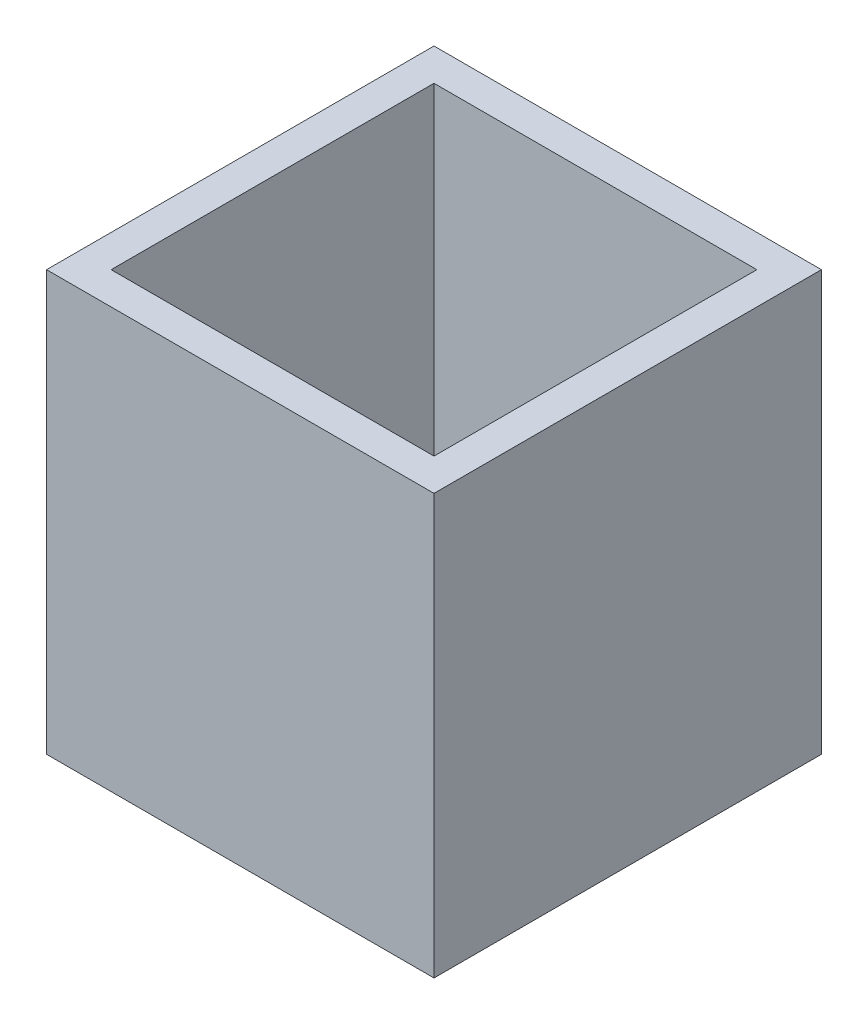
from build123d import *

# Parameters (mm, degrees)
SKETCH1_W           = 60
SKETCH1_H           = 60
SKETCH1_W_2         = 50
SKETCH1_H_2         = 50
BOSS_EXTRUDE1_DEPTH = 60
SKETCH2_W           = 60
SKETCH2_H           = 60
BOSS_EXTRUDE2_DEPTH = 5
SKETCH3_R           = 1.25
CUT_EXTRUDE1_DEPTH  = 5
CUT_EXTRUDE2_REACH  = 62
SKETCH4_R           = 1.25


with BuildPart() as part:
    # Sketch1 → Boss-Extrude1 (new body)
    with BuildSketch(Plane(origin=(0, 0, 0), x_dir=(1, 0, 0), z_dir=(0, 1, 0))):
        Rectangle(SKETCH1_W, SKETCH1_H)
        Rectangle(SKETCH1_W_2, SKETCH1_H_2, mode=Mode.SUBTRACT)
    extrude(amount=BOSS_EXTRUDE1_DEPTH)

    # Sketch2 → Boss-Extrude2 (add)
    with BuildSketch(Plane.XZ):
        Rectangle(SKETCH2_W, SKETCH2_H)
    extrude(amount=BOSS_EXTRUDE2_DEPTH)

    # Sketch3 → Cut-Extrude1 (cut)
    with BuildSketch(Plane(origin=(0, 0, -30), x_dir=(-1, 0, 0), z_dir=(0, 0, -1))):
        with Locations((0, 2.5)):
            Circle(SKETCH3_R)
        with Locations((0, 8.1)):
            Circle(SKETCH3_R)
    extrude(amount=-CUT_EXTRUDE1_DEPTH, mode=Mode.SUBTRACT)

    # Sketch4 → Cut-Extrude2 (cut, up to next)
    with BuildSketch(Plane(origin=(0, 0, -30), x_dir=(-1, 0, 0), z_dir=(0, 0, -1)), mode=Mode.PRIVATE) as cut_extrude2_sk1:
        with Locations((-13.176528006, 8.1)):
            Circle(SKETCH4_R)
    cut_extrude2_tool1 = extrude(cut_extrude2_sk1.sketch, amount=-CUT_EXTRUDE2_REACH, mode=Mode.PRIVATE) & part.part
    add(cut_extrude2_tool1.solids().sort_by_distance((13.176528, 8.1, -30))[0], mode=Mode.SUBTRACT)


solid = part.part
